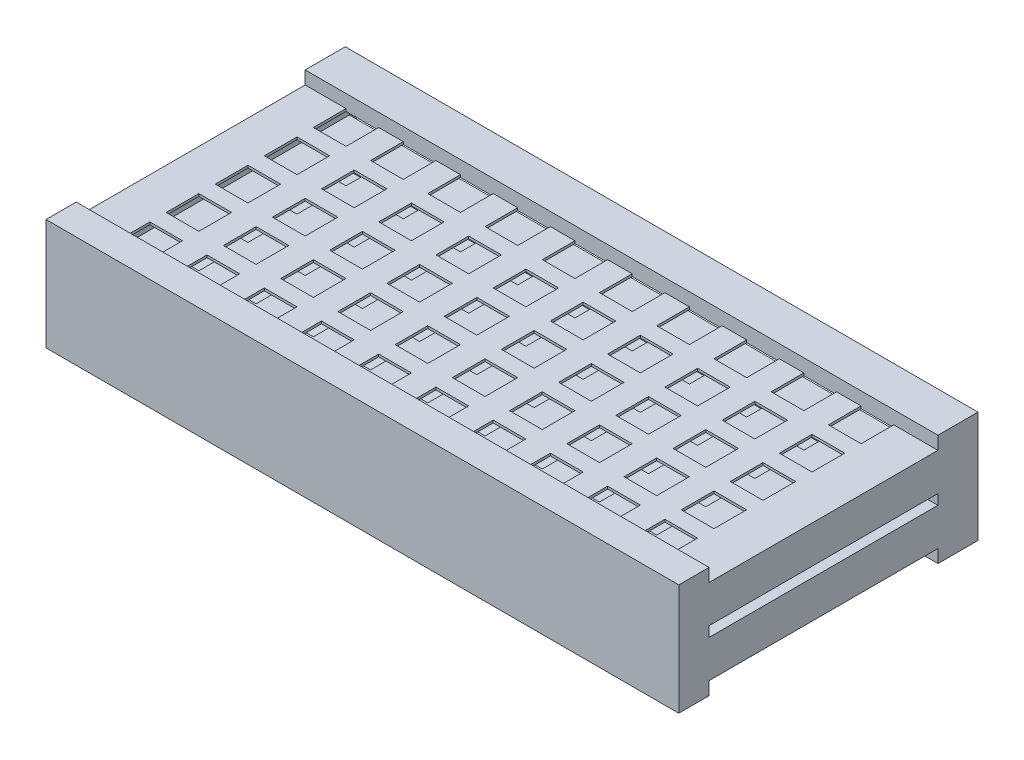
from build123d import *

# Parameters (mm, degrees)
SZKIC1_W                     = 374
SZKIC1_H                     = 53
DODANIE_WYCI_GNI_CIE1_DEPTH  = 177
SZKIC5_W                     = 20
SZKIC5_H                     = 20
WYTNIJ_WYCI_GNI_CIE4_DEPTH   = 104
SZKIC7_W                     = 370
SZKIC7_H                     = 19.4
WYTNIJ_WYCI_GNI_CIE5_DEPTH   = 175
SZKIC9_W                     = 140
SZKIC9_H                     = 6.2
WYTNIJ_WYCI_GNI_CIE6_DEPTH   = 374
SZKIC15_W                    = 374
SZKIC15_H                    = 177
SZKIC15_W_2                  = 20
SZKIC15_H_2                  = 20
DODANIE_WYCI_GNI_CIE6_DEPTH  = 1
SZKIC16_W                    = 374
SZKIC16_H                    = 177
SZKIC16_W_2                  = 20
SZKIC16_H_2                  = 20
DODANIE_WYCI_GNI_CIE7_DEPTH  = 1
SZKIC17_W                    = 177
SZKIC17_H                    = 55
SZKIC17_W_2                  = 140
SZKIC17_H_2                  = 6.2
DODANIE_WYCI_GNI_CIE8_DEPTH  = 1
SZKIC18_W                    = 177
SZKIC18_H                    = 55
SZKIC18_W_2                  = 140
SZKIC18_H_2                  = 6.2
DODANIE_WYCI_GNI_CIE9_DEPTH  = 1
SZKIC19_W                    = 376
SZKIC19_H                    = 55
SZKIC19_W_2                  = 373
SZKIC19_H_2                  = 52
DODANIE_WYCI_GNI_CIE10_DEPTH = 6
SZKIC21_W                    = 376
SZKIC21_H                    = 140
WYTNIJ_WYCI_GNI_CIE7_DEPTH   = 1.5
SZKIC22_W                    = 376
SZKIC22_H                    = 140
WYTNIJ_WYCI_GNI_CIE8_DEPTH   = 1.5
SZKIC23_W                    = 376
SZKIC23_H                    = 24.5
DODANIE_WYCI_GNI_CIE11_DEPTH = 6.5
SZKIC24_W                    = 376
SZKIC24_H                    = 18.5
DODANIE_WYCI_GNI_CIE12_DEPTH = 6.5
SZKIC25_W                    = 376
SZKIC25_H                    = 24.5
DODANIE_WYCI_GNI_CIE13_DEPTH = 6.5
SZKIC26_W                    = 376
SZKIC26_H                    = 18.5
DODANIE_WYCI_GNI_CIE14_DEPTH = 6.5
SZKIC27_W                    = 140
SZKIC27_H                    = 6.2
DODANIE_WYCI_GNI_CIE15_DEPTH = 5.5
SZKIC28_W                    = 140
SZKIC28_H                    = 6.2
DODANIE_WYCI_GNI_CIE16_DEPTH = 5.5


with BuildPart() as part:
    # Szkic1 → Dodanie-wyciągnięcie1 (new body)
    with BuildSketch(Plane.XY):
        with Locations((-1, 7.6)):
            Rectangle(SZKIC1_W, SZKIC1_H)
    extrude(amount=DODANIE_WYCI_GNI_CIE1_DEPTH)

    # Szkic5 → Wytnij-wyciągnięcie4 (cut)
    with BuildSketch(Plane.XZ.offset(18.9)):
        with Locations((155.5, 58.5)):
            Rectangle(SZKIC5_W, SZKIC5_H)
        with Locations((155.5, 28.5)):
            Rectangle(SZKIC5_W, SZKIC5_H)
        with Locations((155.5, 88.5)):
            Rectangle(SZKIC5_W, SZKIC5_H)
        with Locations((155.5, 118.5)):
            Rectangle(SZKIC5_W, SZKIC5_H)
        with Locations((155.5, 148.5)):
            Rectangle(SZKIC5_W, SZKIC5_H)
        with Locations((120.5, 58.5)):
            Rectangle(SZKIC5_W, SZKIC5_H)
        with Locations((120.5, 28.5)):
            Rectangle(SZKIC5_W, SZKIC5_H)
        with Locations((120.5, 88.5)):
            Rectangle(SZKIC5_W, SZKIC5_H)
        with Locations((120.5, 118.5)):
            Rectangle(SZKIC5_W, SZKIC5_H)
        with Locations((120.5, 148.5)):
            Rectangle(SZKIC5_W, SZKIC5_H)
        with Locations((85.5, 58.5)):
            Rectangle(SZKIC5_W, SZKIC5_H)
        with Locations((85.5, 28.5)):
            Rectangle(SZKIC5_W, SZKIC5_H)
        with Locations((85.5, 88.5)):
            Rectangle(SZKIC5_W, SZKIC5_H)
        with Locations((85.5, 118.5)):
            Rectangle(SZKIC5_W, SZKIC5_H)
        with Locations((85.5, 148.5)):
            Rectangle(SZKIC5_W, SZKIC5_H)
        with Locations((50.5, 58.5)):
            Rectangle(SZKIC5_W, SZKIC5_H)
        with Locations((50.5, 28.5)):
            Rectangle(SZKIC5_W, SZKIC5_H)
        with Locations((50.5, 88.5)):
            Rectangle(SZKIC5_W, SZKIC5_H)
        with Locations((50.5, 118.5)):
            Rectangle(SZKIC5_W, SZKIC5_H)
        with Locations((50.5, 148.5)):
            Rectangle(SZKIC5_W, SZKIC5_H)
        with Locations((15.5, 58.5)):
            Rectangle(SZKIC5_W, SZKIC5_H)
        with Locations((15.5, 28.5)):
            Rectangle(SZKIC5_W, SZKIC5_H)
        with Locations((15.5, 88.5)):
            Rectangle(SZKIC5_W, SZKIC5_H)
        with Locations((15.5, 118.5)):
            Rectangle(SZKIC5_W, SZKIC5_H)
        with Locations((15.5, 148.5)):
            Rectangle(SZKIC5_W, SZKIC5_H)
        with Locations((-19.5, 58.5)):
            Rectangle(SZKIC5_W, SZKIC5_H)
        with Locations((-19.5, 28.5)):
            Rectangle(SZKIC5_W, SZKIC5_H)
        with Locations((-19.5, 88.5)):
            Rectangle(SZKIC5_W, SZKIC5_H)
        with Locations((-19.5, 118.5)):
            Rectangle(SZKIC5_W, SZKIC5_H)
        with Locations((-19.5, 148.5)):
            Rectangle(SZKIC5_W, SZKIC5_H)
        with Locations((-54.5, 58.5)):
            Rectangle(SZKIC5_W, SZKIC5_H)
        with Locations((-54.5, 28.5)):
            Rectangle(SZKIC5_W, SZKIC5_H)
        with Locations((-54.5, 88.5)):
            Rectangle(SZKIC5_W, SZKIC5_H)
        with Locations((-54.5, 118.5)):
            Rectangle(SZKIC5_W, SZKIC5_H)
        with Locations((-54.5, 148.5)):
            Rectangle(SZKIC5_W, SZKIC5_H)
        with Locations((-89.5, 58.5)):
            Rectangle(SZKIC5_W, SZKIC5_H)
        with Locations((-89.5, 28.5)):
            Rectangle(SZKIC5_W, SZKIC5_H)
        with Locations((-89.5, 88.5)):
            Rectangle(SZKIC5_W, SZKIC5_H)
        with Locations((-89.5, 118.5)):
            Rectangle(SZKIC5_W, SZKIC5_H)
        with Locations((-89.5, 148.5)):
            Rectangle(SZKIC5_W, SZKIC5_H)
        with Locations((-124.5, 58.5)):
            Rectangle(SZKIC5_W, SZKIC5_H)
        with Locations((-124.5, 28.5)):
            Rectangle(SZKIC5_W, SZKIC5_H)
        with Locations((-124.5, 88.5)):
            Rectangle(SZKIC5_W, SZKIC5_H)
        with Locations((-124.5, 118.5)):
            Rectangle(SZKIC5_W, SZKIC5_H)
        with Locations((-124.5, 148.5)):
            Rectangle(SZKIC5_W, SZKIC5_H)
        with Locations((-159.5, 58.5)):
            Rectangle(SZKIC5_W, SZKIC5_H)
        with Locations((-159.5, 28.5)):
            Rectangle(SZKIC5_W, SZKIC5_H)
        with Locations((-159.5, 88.5)):
            Rectangle(SZKIC5_W, SZKIC5_H)
        with Locations((-159.5, 118.5)):
            Rectangle(SZKIC5_W, SZKIC5_H)
        with Locations((-159.5, 148.5)):
            Rectangle(SZKIC5_W, SZKIC5_H)
    extrude(amount=-WYTNIJ_WYCI_GNI_CIE4_DEPTH, mode=Mode.SUBTRACT)

    # Szkic7 → Wytnij-wyciągnięcie5 (cut)
    with BuildSketch(Plane(origin=(0, 0, 0), x_dir=(-1, 0, 0), z_dir=(0, 0, -1))):
        with Locations((1, 22.4)):
            Rectangle(SZKIC7_W, SZKIC7_H)
        with Locations((1, -7.2)):
            Rectangle(SZKIC7_W, SZKIC7_H)
    extrude(amount=-WYTNIJ_WYCI_GNI_CIE5_DEPTH, mode=Mode.SUBTRACT)

    # Szkic9 → Wytnij-wyciągnięcie6 (cut)
    with BuildSketch(Plane(origin=(186, 0, 0), x_dir=(0, 0, -1), z_dir=(1, 0, 0))):
        with Locations((-88.5, 7.6)):
            Rectangle(SZKIC9_W, SZKIC9_H)
    extrude(amount=-WYTNIJ_WYCI_GNI_CIE6_DEPTH, mode=Mode.SUBTRACT)

    # Szkic15 → Dodanie-wyciągnięcie6 (add)
    with BuildSketch(Plane(origin=(0, 34.1, 0), x_dir=(1, 0, 0), z_dir=(0, 1, 0))):
        with Locations((-1, -88.5)):
            Rectangle(SZKIC15_W, SZKIC15_H)
        with Locations((-159.5, -28.5)):
            Rectangle(SZKIC15_W_2, SZKIC15_H_2, mode=Mode.SUBTRACT)
        with Locations((-124.5, -28.5)):
            Rectangle(SZKIC15_W_2, SZKIC15_H_2, mode=Mode.SUBTRACT)
        with Locations((-89.5, -28.5)):
            Rectangle(SZKIC15_W_2, SZKIC15_H_2, mode=Mode.SUBTRACT)
        with Locations((-54.5, -28.5)):
            Rectangle(SZKIC15_W_2, SZKIC15_H_2, mode=Mode.SUBTRACT)
        with Locations((-19.5, -28.5)):
            Rectangle(SZKIC15_W_2, SZKIC15_H_2, mode=Mode.SUBTRACT)
        with Locations((15.5, -28.5)):
            Rectangle(SZKIC15_W_2, SZKIC15_H_2, mode=Mode.SUBTRACT)
        with Locations((50.5, -28.5)):
            Rectangle(SZKIC15_W_2, SZKIC15_H_2, mode=Mode.SUBTRACT)
        with Locations((85.5, -28.5)):
            Rectangle(SZKIC15_W_2, SZKIC15_H_2, mode=Mode.SUBTRACT)
        with Locations((120.5, -28.5)):
            Rectangle(SZKIC15_W_2, SZKIC15_H_2, mode=Mode.SUBTRACT)
        with Locations((155.5, -28.5)):
            Rectangle(SZKIC15_W_2, SZKIC15_H_2, mode=Mode.SUBTRACT)
        with Locations((155.5, -58.5)):
            Rectangle(SZKIC15_W_2, SZKIC15_H_2, mode=Mode.SUBTRACT)
        with Locations((155.5, -88.5)):
            Rectangle(SZKIC15_W_2, SZKIC15_H_2, mode=Mode.SUBTRACT)
        with Locations((155.5, -118.5)):
            Rectangle(SZKIC15_W_2, SZKIC15_H_2, mode=Mode.SUBTRACT)
        with Locations((155.5, -148.5)):
            Rectangle(SZKIC15_W_2, SZKIC15_H_2, mode=Mode.SUBTRACT)
        with Locations((120.5, -58.5)):
            Rectangle(SZKIC15_W_2, SZKIC15_H_2, mode=Mode.SUBTRACT)
        with Locations((120.5, -88.5)):
            Rectangle(SZKIC15_W_2, SZKIC15_H_2, mode=Mode.SUBTRACT)
        with Locations((120.5, -118.5)):
            Rectangle(SZKIC15_W_2, SZKIC15_H_2, mode=Mode.SUBTRACT)
        with Locations((120.5, -148.5)):
            Rectangle(SZKIC15_W_2, SZKIC15_H_2, mode=Mode.SUBTRACT)
        with Locations((85.5, -58.5)):
            Rectangle(SZKIC15_W_2, SZKIC15_H_2, mode=Mode.SUBTRACT)
        with Locations((85.5, -88.5)):
            Rectangle(SZKIC15_W_2, SZKIC15_H_2, mode=Mode.SUBTRACT)
        with Locations((85.5, -118.5)):
            Rectangle(SZKIC15_W_2, SZKIC15_H_2, mode=Mode.SUBTRACT)
        with Locations((85.5, -148.5)):
            Rectangle(SZKIC15_W_2, SZKIC15_H_2, mode=Mode.SUBTRACT)
        with Locations((50.5, -58.5)):
            Rectangle(SZKIC15_W_2, SZKIC15_H_2, mode=Mode.SUBTRACT)
        with Locations((50.5, -88.5)):
            Rectangle(SZKIC15_W_2, SZKIC15_H_2, mode=Mode.SUBTRACT)
        with Locations((50.5, -118.5)):
            Rectangle(SZKIC15_W_2, SZKIC15_H_2, mode=Mode.SUBTRACT)
        with Locations((15.5, -58.5)):
            Rectangle(SZKIC15_W_2, SZKIC15_H_2, mode=Mode.SUBTRACT)
        with Locations((15.5, -88.5)):
            Rectangle(SZKIC15_W_2, SZKIC15_H_2, mode=Mode.SUBTRACT)
        with Locations((15.5, -118.5)):
            Rectangle(SZKIC15_W_2, SZKIC15_H_2, mode=Mode.SUBTRACT)
        with Locations((15.5, -148.5)):
            Rectangle(SZKIC15_W_2, SZKIC15_H_2, mode=Mode.SUBTRACT)
        with Locations((50.5, -148.5)):
            Rectangle(SZKIC15_W_2, SZKIC15_H_2, mode=Mode.SUBTRACT)
        with Locations((-19.5, -58.5)):
            Rectangle(SZKIC15_W_2, SZKIC15_H_2, mode=Mode.SUBTRACT)
        with Locations((-19.5, -88.5)):
            Rectangle(SZKIC15_W_2, SZKIC15_H_2, mode=Mode.SUBTRACT)
        with Locations((-19.5, -118.5)):
            Rectangle(SZKIC15_W_2, SZKIC15_H_2, mode=Mode.SUBTRACT)
        with Locations((-19.5, -148.5)):
            Rectangle(SZKIC15_W_2, SZKIC15_H_2, mode=Mode.SUBTRACT)
        with Locations((-54.5, -58.5)):
            Rectangle(SZKIC15_W_2, SZKIC15_H_2, mode=Mode.SUBTRACT)
        with Locations((-54.5, -88.5)):
            Rectangle(SZKIC15_W_2, SZKIC15_H_2, mode=Mode.SUBTRACT)
        with Locations((-54.5, -118.5)):
            Rectangle(SZKIC15_W_2, SZKIC15_H_2, mode=Mode.SUBTRACT)
        with Locations((-54.5, -148.5)):
            Rectangle(SZKIC15_W_2, SZKIC15_H_2, mode=Mode.SUBTRACT)
        with Locations((-89.5, -58.5)):
            Rectangle(SZKIC15_W_2, SZKIC15_H_2, mode=Mode.SUBTRACT)
        with Locations((-89.5, -88.5)):
            Rectangle(SZKIC15_W_2, SZKIC15_H_2, mode=Mode.SUBTRACT)
        with Locations((-89.5, -118.5)):
            Rectangle(SZKIC15_W_2, SZKIC15_H_2, mode=Mode.SUBTRACT)
        with Locations((-89.5, -148.5)):
            Rectangle(SZKIC15_W_2, SZKIC15_H_2, mode=Mode.SUBTRACT)
        with Locations((-124.5, -58.5)):
            Rectangle(SZKIC15_W_2, SZKIC15_H_2, mode=Mode.SUBTRACT)
        with Locations((-124.5, -88.5)):
            Rectangle(SZKIC15_W_2, SZKIC15_H_2, mode=Mode.SUBTRACT)
        with Locations((-124.5, -118.5)):
            Rectangle(SZKIC15_W_2, SZKIC15_H_2, mode=Mode.SUBTRACT)
        with Locations((-124.5, -148.5)):
            Rectangle(SZKIC15_W_2, SZKIC15_H_2, mode=Mode.SUBTRACT)
        with Locations((-159.5, -58.5)):
            Rectangle(SZKIC15_W_2, SZKIC15_H_2, mode=Mode.SUBTRACT)
        with Locations((-159.5, -88.5)):
            Rectangle(SZKIC15_W_2, SZKIC15_H_2, mode=Mode.SUBTRACT)
        with Locations((-159.5, -118.5)):
            Rectangle(SZKIC15_W_2, SZKIC15_H_2, mode=Mode.SUBTRACT)
        with Locations((-159.5, -148.5)):
            Rectangle(SZKIC15_W_2, SZKIC15_H_2, mode=Mode.SUBTRACT)
    extrude(amount=DODANIE_WYCI_GNI_CIE6_DEPTH)

    # Szkic16 → Dodanie-wyciągnięcie7 (add)
    with BuildSketch(Plane.XZ.offset(18.9)):
        with Locations((-1, 88.5)):
            Rectangle(SZKIC16_W, SZKIC16_H)
        with Locations((155.5, 28.5)):
            Rectangle(SZKIC16_W_2, SZKIC16_H_2, mode=Mode.SUBTRACT)
        with Locations((120.5, 28.5)):
            Rectangle(SZKIC16_W_2, SZKIC16_H_2, mode=Mode.SUBTRACT)
        with Locations((85.5, 28.5)):
            Rectangle(SZKIC16_W_2, SZKIC16_H_2, mode=Mode.SUBTRACT)
        with Locations((50.5, 28.5)):
            Rectangle(SZKIC16_W_2, SZKIC16_H_2, mode=Mode.SUBTRACT)
        with Locations((15.5, 28.5)):
            Rectangle(SZKIC16_W_2, SZKIC16_H_2, mode=Mode.SUBTRACT)
        with Locations((-19.5, 28.5)):
            Rectangle(SZKIC16_W_2, SZKIC16_H_2, mode=Mode.SUBTRACT)
        with Locations((-54.5, 28.5)):
            Rectangle(SZKIC16_W_2, SZKIC16_H_2, mode=Mode.SUBTRACT)
        with Locations((-89.5, 28.5)):
            Rectangle(SZKIC16_W_2, SZKIC16_H_2, mode=Mode.SUBTRACT)
        with Locations((-124.5, 28.5)):
            Rectangle(SZKIC16_W_2, SZKIC16_H_2, mode=Mode.SUBTRACT)
        with Locations((-159.5, 28.5)):
            Rectangle(SZKIC16_W_2, SZKIC16_H_2, mode=Mode.SUBTRACT)
        with Locations((155.5, 58.5)):
            Rectangle(SZKIC16_W_2, SZKIC16_H_2, mode=Mode.SUBTRACT)
        with Locations((120.5, 58.5)):
            Rectangle(SZKIC16_W_2, SZKIC16_H_2, mode=Mode.SUBTRACT)
        with Locations((85.5, 58.5)):
            Rectangle(SZKIC16_W_2, SZKIC16_H_2, mode=Mode.SUBTRACT)
        with Locations((50.5, 58.5)):
            Rectangle(SZKIC16_W_2, SZKIC16_H_2, mode=Mode.SUBTRACT)
        with Locations((15.5, 58.5)):
            Rectangle(SZKIC16_W_2, SZKIC16_H_2, mode=Mode.SUBTRACT)
        with Locations((-19.5, 58.5)):
            Rectangle(SZKIC16_W_2, SZKIC16_H_2, mode=Mode.SUBTRACT)
        with Locations((-54.5, 58.5)):
            Rectangle(SZKIC16_W_2, SZKIC16_H_2, mode=Mode.SUBTRACT)
        with Locations((-89.5, 58.5)):
            Rectangle(SZKIC16_W_2, SZKIC16_H_2, mode=Mode.SUBTRACT)
        with Locations((-124.5, 58.5)):
            Rectangle(SZKIC16_W_2, SZKIC16_H_2, mode=Mode.SUBTRACT)
        with Locations((-159.5, 58.5)):
            Rectangle(SZKIC16_W_2, SZKIC16_H_2, mode=Mode.SUBTRACT)
        with Locations((-159.5, 88.5)):
            Rectangle(SZKIC16_W_2, SZKIC16_H_2, mode=Mode.SUBTRACT)
        with Locations((-159.5, 118.5)):
            Rectangle(SZKIC16_W_2, SZKIC16_H_2, mode=Mode.SUBTRACT)
        with Locations((-159.5, 148.5)):
            Rectangle(SZKIC16_W_2, SZKIC16_H_2, mode=Mode.SUBTRACT)
        with Locations((-124.5, 88.5)):
            Rectangle(SZKIC16_W_2, SZKIC16_H_2, mode=Mode.SUBTRACT)
        with Locations((-124.5, 118.5)):
            Rectangle(SZKIC16_W_2, SZKIC16_H_2, mode=Mode.SUBTRACT)
        with Locations((-124.5, 148.5)):
            Rectangle(SZKIC16_W_2, SZKIC16_H_2, mode=Mode.SUBTRACT)
        with Locations((-89.5, 88.5)):
            Rectangle(SZKIC16_W_2, SZKIC16_H_2, mode=Mode.SUBTRACT)
        with Locations((-89.5, 118.5)):
            Rectangle(SZKIC16_W_2, SZKIC16_H_2, mode=Mode.SUBTRACT)
        with Locations((-89.5, 148.5)):
            Rectangle(SZKIC16_W_2, SZKIC16_H_2, mode=Mode.SUBTRACT)
        with Locations((-54.5, 88.5)):
            Rectangle(SZKIC16_W_2, SZKIC16_H_2, mode=Mode.SUBTRACT)
        with Locations((-54.5, 118.5)):
            Rectangle(SZKIC16_W_2, SZKIC16_H_2, mode=Mode.SUBTRACT)
        with Locations((-54.5, 148.5)):
            Rectangle(SZKIC16_W_2, SZKIC16_H_2, mode=Mode.SUBTRACT)
        with Locations((-19.5, 88.5)):
            Rectangle(SZKIC16_W_2, SZKIC16_H_2, mode=Mode.SUBTRACT)
        with Locations((-19.5, 118.5)):
            Rectangle(SZKIC16_W_2, SZKIC16_H_2, mode=Mode.SUBTRACT)
        with Locations((-19.5, 148.5)):
            Rectangle(SZKIC16_W_2, SZKIC16_H_2, mode=Mode.SUBTRACT)
        with Locations((15.5, 88.5)):
            Rectangle(SZKIC16_W_2, SZKIC16_H_2, mode=Mode.SUBTRACT)
        with Locations((15.5, 118.5)):
            Rectangle(SZKIC16_W_2, SZKIC16_H_2, mode=Mode.SUBTRACT)
        with Locations((15.5, 148.5)):
            Rectangle(SZKIC16_W_2, SZKIC16_H_2, mode=Mode.SUBTRACT)
        with Locations((50.5, 88.5)):
            Rectangle(SZKIC16_W_2, SZKIC16_H_2, mode=Mode.SUBTRACT)
        with Locations((50.5, 118.5)):
            Rectangle(SZKIC16_W_2, SZKIC16_H_2, mode=Mode.SUBTRACT)
        with Locations((50.5, 148.5)):
            Rectangle(SZKIC16_W_2, SZKIC16_H_2, mode=Mode.SUBTRACT)
        with Locations((85.5, 88.5)):
            Rectangle(SZKIC16_W_2, SZKIC16_H_2, mode=Mode.SUBTRACT)
        with Locations((85.5, 118.5)):
            Rectangle(SZKIC16_W_2, SZKIC16_H_2, mode=Mode.SUBTRACT)
        with Locations((85.5, 148.5)):
            Rectangle(SZKIC16_W_2, SZKIC16_H_2, mode=Mode.SUBTRACT)
        with Locations((120.5, 88.5)):
            Rectangle(SZKIC16_W_2, SZKIC16_H_2, mode=Mode.SUBTRACT)
        with Locations((155.5, 88.5)):
            Rectangle(SZKIC16_W_2, SZKIC16_H_2, mode=Mode.SUBTRACT)
        with Locations((155.5, 118.5)):
            Rectangle(SZKIC16_W_2, SZKIC16_H_2, mode=Mode.SUBTRACT)
        with Locations((120.5, 118.5)):
            Rectangle(SZKIC16_W_2, SZKIC16_H_2, mode=Mode.SUBTRACT)
        with Locations((155.5, 148.5)):
            Rectangle(SZKIC16_W_2, SZKIC16_H_2, mode=Mode.SUBTRACT)
        with Locations((120.5, 148.5)):
            Rectangle(SZKIC16_W_2, SZKIC16_H_2, mode=Mode.SUBTRACT)
    extrude(amount=DODANIE_WYCI_GNI_CIE7_DEPTH)

    # Szkic17 → Dodanie-wyciągnięcie8 (add)
    with BuildSketch(Plane(origin=(186, 0, 0), x_dir=(0, 0, -1), z_dir=(1, 0, 0))):
        with Locations((-88.5, 7.6)):
            Rectangle(SZKIC17_W, SZKIC17_H)
        with Locations((-88.5, 7.6)):
            Rectangle(SZKIC17_W_2, SZKIC17_H_2, mode=Mode.SUBTRACT)
    extrude(amount=DODANIE_WYCI_GNI_CIE8_DEPTH)

    # Szkic18 → Dodanie-wyciągnięcie9 (add)
    with BuildSketch(Plane.ZY.offset(188)):
        with Locations((88.5, 7.6)):
            Rectangle(SZKIC18_W, SZKIC18_H)
        with Locations((88.5, 7.6)):
            Rectangle(SZKIC18_W_2, SZKIC18_H_2, mode=Mode.SUBTRACT)
    extrude(amount=DODANIE_WYCI_GNI_CIE9_DEPTH)

    # Szkic19 → Dodanie-wyciągnięcie10 (add)
    with BuildSketch(Plane(origin=(0, 0, 0), x_dir=(-1, 0, 0), z_dir=(0, 0, -1))):
        with Locations((1, 7.6)):
            Rectangle(SZKIC19_W, SZKIC19_H)
        with Locations((1, 7.6)):
            Rectangle(SZKIC19_W_2, SZKIC19_H_2, mode=Mode.SUBTRACT)
    extrude(amount=DODANIE_WYCI_GNI_CIE10_DEPTH)

    # Szkic21 → Wytnij-wyciągnięcie7 (cut)
    with BuildSketch(Plane(origin=(0, 35.1, 0), x_dir=(1, 0, 0), z_dir=(0, 1, 0))):
        with Locations((-1, -88.5)):
            Rectangle(SZKIC21_W, SZKIC21_H)
    extrude(amount=-WYTNIJ_WYCI_GNI_CIE7_DEPTH, mode=Mode.SUBTRACT)

    # Szkic22 → Wytnij-wyciągnięcie8 (cut)
    with BuildSketch(Plane.XZ.offset(19.9)):
        with Locations((-1, 88.5)):
            Rectangle(SZKIC22_W, SZKIC22_H)
    extrude(amount=-WYTNIJ_WYCI_GNI_CIE8_DEPTH, mode=Mode.SUBTRACT)

    # Szkic23 → Dodanie-wyciągnięcie11 (add)
    with BuildSketch(Plane.XZ.offset(19.9)):
        with Locations((-1, 6.25)):
            Rectangle(SZKIC23_W, SZKIC23_H)
    extrude(amount=DODANIE_WYCI_GNI_CIE11_DEPTH)

    # Szkic24 → Dodanie-wyciągnięcie12 (add)
    with BuildSketch(Plane.XZ.offset(19.9)):
        with Locations((-1, 167.75)):
            Rectangle(SZKIC24_W, SZKIC24_H)
    extrude(amount=DODANIE_WYCI_GNI_CIE12_DEPTH)

    # Szkic25 → Dodanie-wyciągnięcie13 (add)
    with BuildSketch(Plane(origin=(0, 35.1, 0), x_dir=(1, 0, 0), z_dir=(0, 1, 0))):
        with Locations((-1, -6.25)):
            Rectangle(SZKIC25_W, SZKIC25_H)
    extrude(amount=DODANIE_WYCI_GNI_CIE13_DEPTH)

    # Szkic26 → Dodanie-wyciągnięcie14 (add)
    with BuildSketch(Plane(origin=(0, 35.1, 0), x_dir=(1, 0, 0), z_dir=(0, 1, 0))):
        with Locations((-1, -167.75)):
            Rectangle(SZKIC26_W, SZKIC26_H)
    extrude(amount=DODANIE_WYCI_GNI_CIE14_DEPTH)

    # Szkic27 → Dodanie-wyciągnięcie15 (add)
    with BuildSketch(Plane(origin=(187, 0, 0), x_dir=(0, 0, -1), z_dir=(1, 0, 0))):
        Polygon((6, 41.6), (6, -26.4), (-18.5, -26.4), (-18.5, -18.4), (-158.5, -18.4), (-158.5, -26.4), (-177, -26.4), (-177, 41.6), (-158.5, 41.6), (-158.5, 33.6), (-18.5, 33.6), (-18.5, 41.6), align=None)
        with Locations((-88.5, 7.6)):
            Rectangle(SZKIC27_W, SZKIC27_H, mode=Mode.SUBTRACT)
    extrude(amount=DODANIE_WYCI_GNI_CIE15_DEPTH)

    # Szkic28 → Dodanie-wyciągnięcie16 (add)
    with BuildSketch(Plane.ZY.offset(189)):
        Polygon((-6, -26.4), (-6, 41.6), (18.5, 41.6), (18.5, 33.6), (158.5, 33.6), (158.5, 41.6), (177, 41.6), (177, -26.4), (158.5, -26.4), (158.5, -18.4), (18.5, -18.4), (18.5, -26.4), align=None)
        with Locations((88.5, 7.6)):
            Rectangle(SZKIC28_W, SZKIC28_H, mode=Mode.SUBTRACT)
    extrude(amount=DODANIE_WYCI_GNI_CIE16_DEPTH)


solid = part.part
